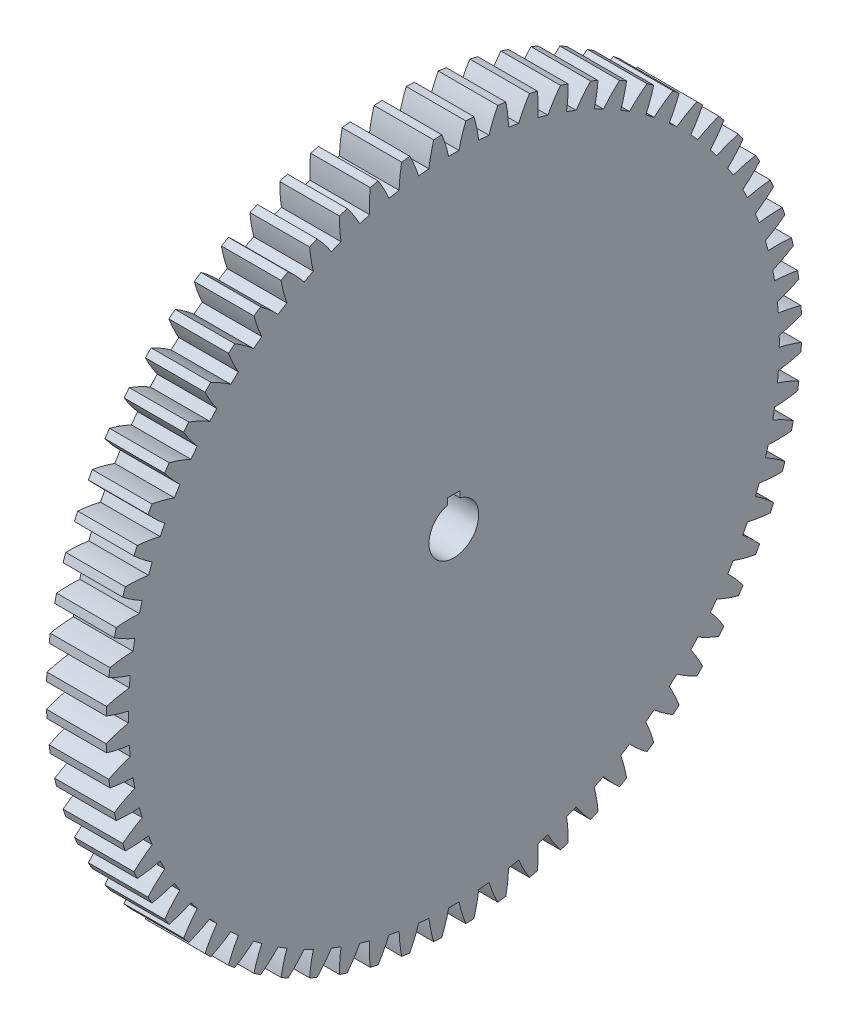
from build123d import *

# Parameters (mm, degrees)
BASPROSKE_W     = 304.8
BASPROSKE_H     = 1778
TOOTHCUT_DEPTH  = 2533.878015223
TEETHCUTS_COUNT = 68
TEETHCUTS_ANGLE = 354.705882353
BORSKE_R        = 127
BORE_DEPTH      = 304.8000508
KEYSKE_W        = 63.5
KEYSKE_H        = 154.8384
KEYWAY_DEPTH    = 304.8000508


with BuildPart() as part:
    # BasProSke → Base-Revolve (revolve)
    with BuildSketch(Plane(origin=(0, 0, 0), x_dir=(1, 0, 0), z_dir=(0, 1, 0)), mode=Mode.PRIVATE) as base_revolve_sk:
        with Locations((152.4, 889)):
            Rectangle(BASPROSKE_W, BASPROSKE_H)
    revolve(base_revolve_sk.sketch.rotate(Axis((-10, 0, 0), (1, 0, 0)), 180), axis=Axis((-10, 0, 0), (1, 0, 0)))

    # TooCutSke → ToothCut (cut, through all)
    with BuildSketch(Plane(origin=(0, 0, 0), x_dir=(0, 0, -1), z_dir=(1, 0, 0))):
        with BuildLine():
            ThreePointArc((26.437338563, 1663.488662821), (0, 1663.69873), (-26.437338563, 1663.488662821))
            ThreePointArc((-26.437338563, 1663.488662821), (-41.453753976, 1720.979040408), (-61.354520204, 1776.966501062))
            ThreePointArc((-61.354520204, 1776.966501062), (0, 1778.0254), (61.354520204, 1776.966501062))
            ThreePointArc((61.354520204, 1776.966501062), (41.453753976, 1720.979040408), (26.437338563, 1663.488662821))
        make_face()
    toothcut = extrude(amount=TOOTHCUT_DEPTH, mode=Mode.SUBTRACT)

    # TeethCuts: ToothCut ×68 about axis
    teethcuts_axis = Axis((-10, 0, 0), (1, 0, 0))
    for i in range(1, TEETHCUTS_COUNT):
        add(toothcut.rotate(teethcuts_axis, i * TEETHCUTS_ANGLE / (TEETHCUTS_COUNT - 1)), mode=Mode.SUBTRACT)

    # BorSke → Bore (cut, symmetric)
    with BuildSketch(Plane(origin=(0, 0, 0), x_dir=(0, 0, -1), z_dir=(1, 0, 0))):
        with Locations(Location((0, 0, 0), (0, 0, 180))):
            Circle(BORSKE_R)
    extrude(amount=BORE_DEPTH, both=True, mode=Mode.SUBTRACT)

    # KeySke → Keyway (cut, symmetric)
    with BuildSketch(Plane(origin=(0, 0, 0), x_dir=(0, 0, -1), z_dir=(1, 0, 0))):
        with Locations((0, 77.4192)):
            Rectangle(KEYSKE_W, KEYSKE_H)
    extrude(amount=KEYWAY_DEPTH, both=True, mode=Mode.SUBTRACT)


solid = part.part
